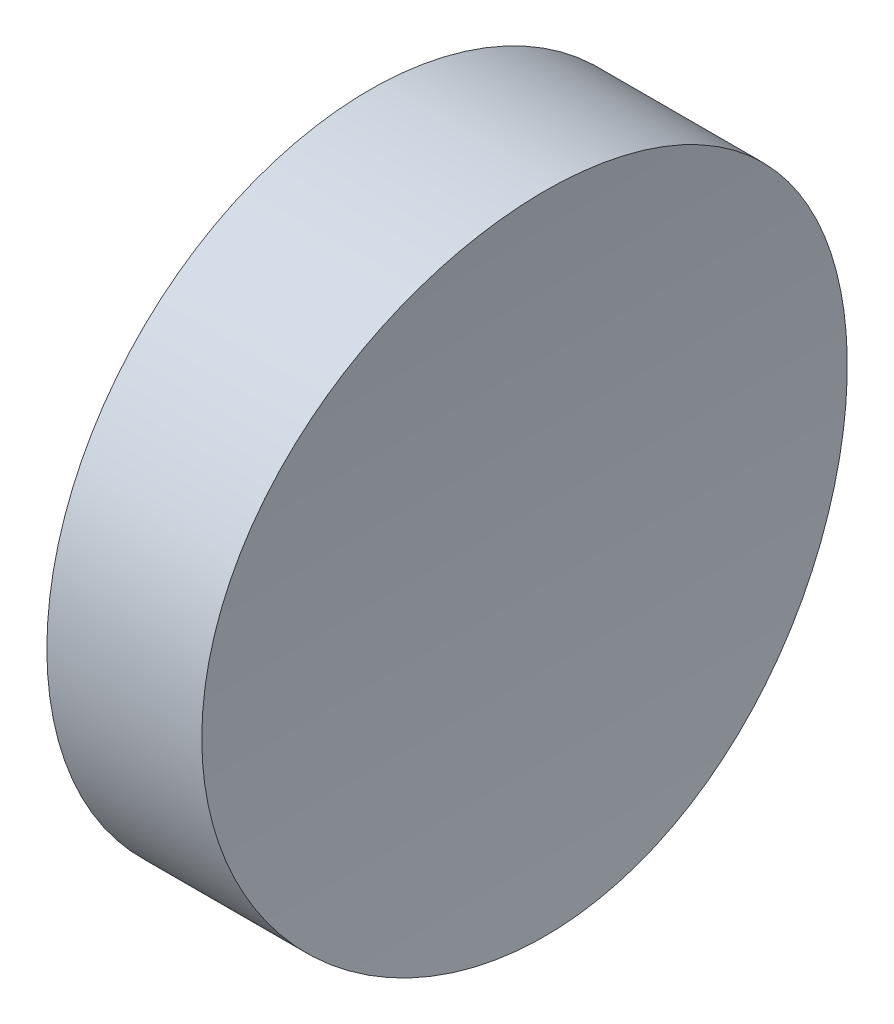
from build123d import *

# Parameters (mm, degrees)
SKETCH_1_R               = 12.5
EXTRUDE_1_DEPTH          = 10
SKETCH_2_R               = 100
CUT_EXTRUDE_1_DEPTH      = 13.5
CUT_EXTRUDE_1_DEPTH_BACK = 13.5


with BuildPart() as part:
    # 草图1 → 凸台-拉伸1 (new body)
    with BuildSketch(Plane(origin=(0, 0, 0), x_dir=(0, 0, -1), z_dir=(1, 0, 0))):
        Circle(SKETCH_1_R)
    extrude(amount=EXTRUDE_1_DEPTH)

    # 草图2 → 切除-拉伸1 (cut, two sides)
    with BuildSketch(Plane.XY) as cut_extrude_1_sk:
        with Locations((106, 0)):
            Circle(SKETCH_2_R)
    extrude(amount=CUT_EXTRUDE_1_DEPTH, mode=Mode.SUBTRACT)
    extrude(cut_extrude_1_sk.sketch, amount=-CUT_EXTRUDE_1_DEPTH_BACK, mode=Mode.SUBTRACT)


solid = part.part
